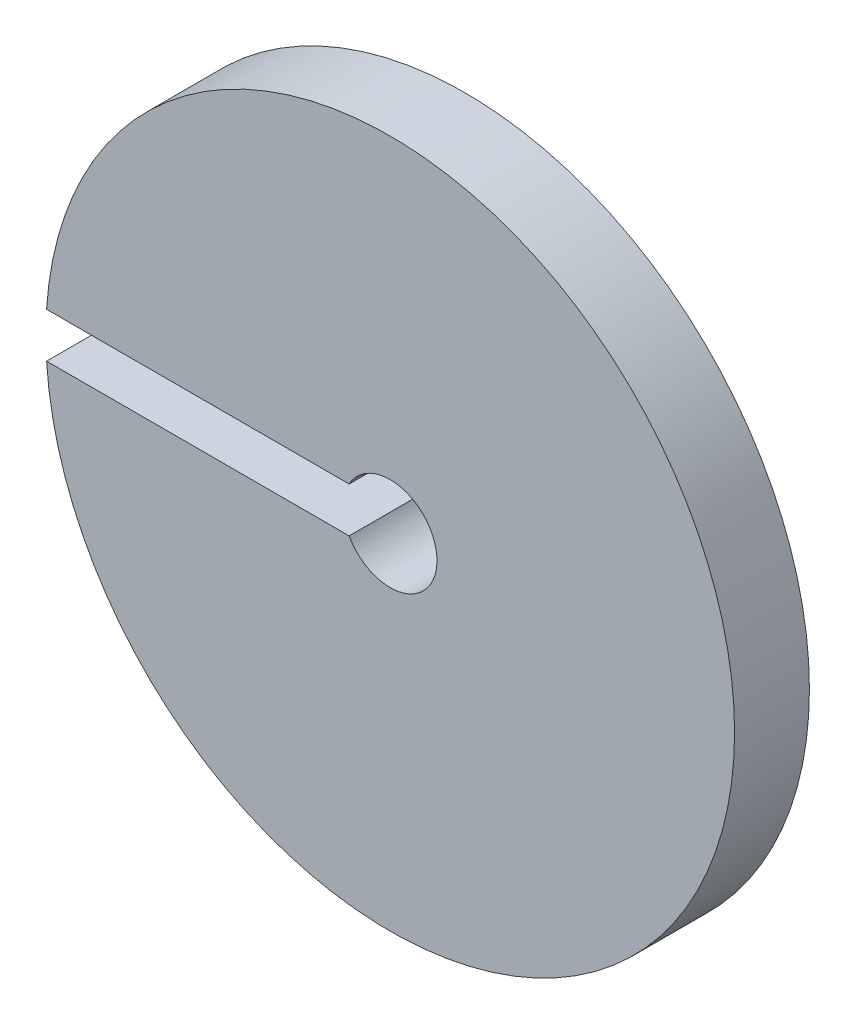
from build123d import *

# Parameters (mm, degrees)
SKETCH1_R           = 23
BOSS_EXTRUDE1_DEPTH = 5
SKETCH2_R           = 3.125
CUT_EXTRUDE1_DEPTH  = 6
SKETCH4_W           = 22.031580043
SKETCH4_H           = 3
CUT_EXTRUDE2_DEPTH  = 6


with BuildPart() as part:
    # Sketch1 → Boss-Extrude1 (new body)
    with BuildSketch(Plane.XY):
        Circle(SKETCH1_R)
    extrude(amount=BOSS_EXTRUDE1_DEPTH)

    # Sketch2 → Cut-Extrude1 (cut, through all)
    with BuildSketch(Plane(origin=(0, 0, 0), x_dir=(-1, 0, 0), z_dir=(0, 0, -1))):
        Circle(SKETCH2_R)
    extrude(amount=-CUT_EXTRUDE1_DEPTH, mode=Mode.SUBTRACT)

    # Sketch4 → Cut-Extrude2 (cut, through all)
    with BuildSketch(Plane(origin=(0, 0, 0), x_dir=(-1, 0, 0), z_dir=(0, 0, -1))):
        with Locations((13.757254046, 0)):
            Rectangle(SKETCH4_W, SKETCH4_H)
    extrude(amount=-CUT_EXTRUDE2_DEPTH, mode=Mode.SUBTRACT)


solid = part.part
